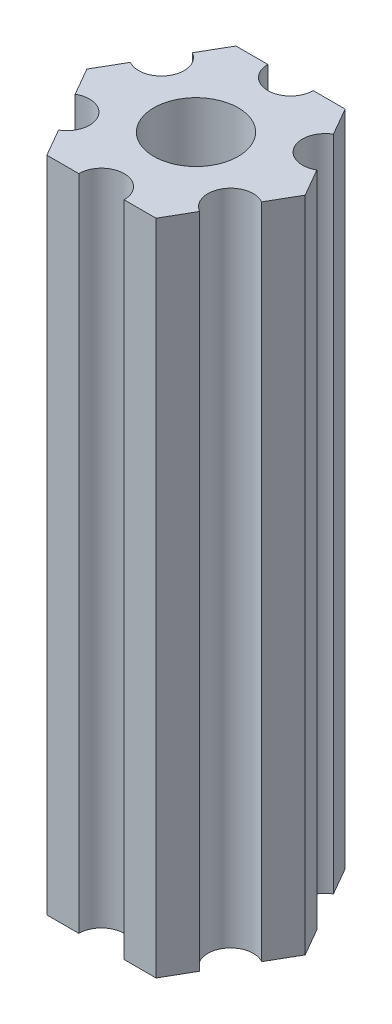
from build123d import *

# Parameters (mm, degrees)
ESBO_O1_R                = 2.79
RESSALTO_EXTRUS_O1_DEPTH = 43.5


with BuildPart() as part:
    # Esboço1 → Ressalto-extrusão1 (new body)
    with BuildSketch(Plane(origin=(0, 85, 0), x_dir=(1, 0, 0), z_dir=(0, 1, 0))):
        with BuildLine():
            Line((6.162658774, -1.825961894), (7.216878365, 0))
            Line((7.216878365, 0), (6.162658774, 1.825961894))
            ThreePointArc((6.162658774, 1.825961894), (4.113620668, 2.375), (4.662658774, 4.424038106))
            Line((4.662658774, 4.424038106), (3.608439182, 6.25))
            Line((3.608439182, 6.25), (1.5, 6.25))
            ThreePointArc((1.5, 6.25), (0, 4.75), (-1.5, 6.25))
            Line((-1.5, 6.25), (-3.608439182, 6.25))
            Line((-3.608439182, 6.25), (-4.662658774, 4.424038106))
            ThreePointArc((-4.662658774, 4.424038106), (-4.113620668, 2.375), (-6.162658774, 1.825961894))
            Line((-6.162658774, 1.825961894), (-7.216878365, 0))
            Line((-7.216878365, 0), (-6.162658774, -1.825961894))
            ThreePointArc((-6.162658774, -1.825961894), (-4.113620668, -2.375), (-4.662658774, -4.424038106))
            Line((-4.662658774, -4.424038106), (-3.608439182, -6.25))
            Line((-3.608439182, -6.25), (-1.5, -6.25))
            ThreePointArc((-1.5, -6.25), (0, -4.75), (1.5, -6.25))
            Line((1.5, -6.25), (3.608439182, -6.25))
            Line((3.608439182, -6.25), (4.662658774, -4.424038106))
            ThreePointArc((4.662658774, -4.424038106), (4.113620668, -2.375), (6.162658774, -1.825961894))
        make_face()
        Circle(ESBO_O1_R, mode=Mode.SUBTRACT)
    extrude(amount=-RESSALTO_EXTRUS_O1_DEPTH)


solid = part.part
